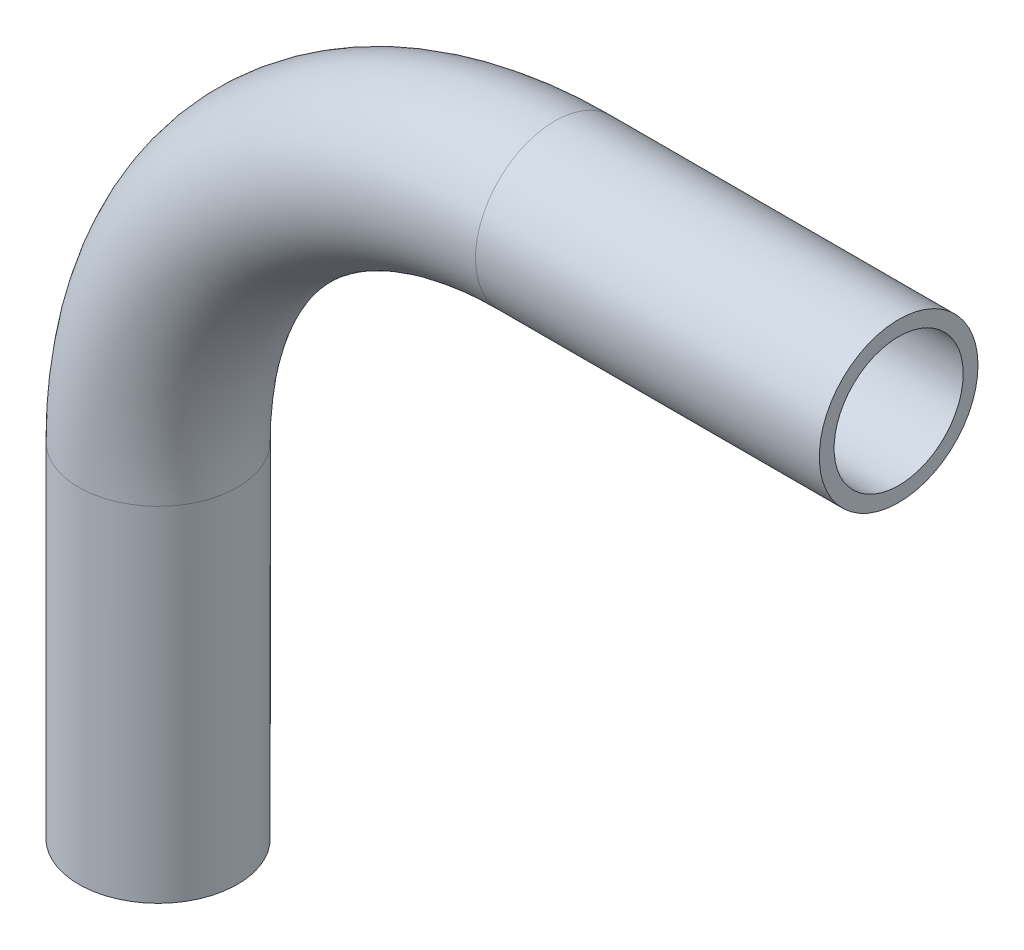
from build123d import *

# Parameters (mm, degrees)
SKETCH2_R   = 4.7625
SKETCH2_R_2 = 3.8735


with BuildPart() as part:
    # Sweep1: sweep along a path in Sketch1
    with BuildLine(Plane.XY) as sweep1_path:
        Line((0, -44.45), (0, -23.8125))
        ThreePointArc((0, -23.8125), (6.974519773, -6.974519773), (23.8125, 0))
        Line((23.8125, 0), (44.45, 0))
    # Sketch2 → Sweep1 (sweep)
    with BuildSketch(Plane(origin=(44.45, 0, 0), x_dir=(0, 0, -1), z_dir=(1, 0, 0))):
        Circle(SKETCH2_R)
        Circle(SKETCH2_R_2, mode=Mode.SUBTRACT)
    sweep(path=sweep1_path.line)


solid = part.part
